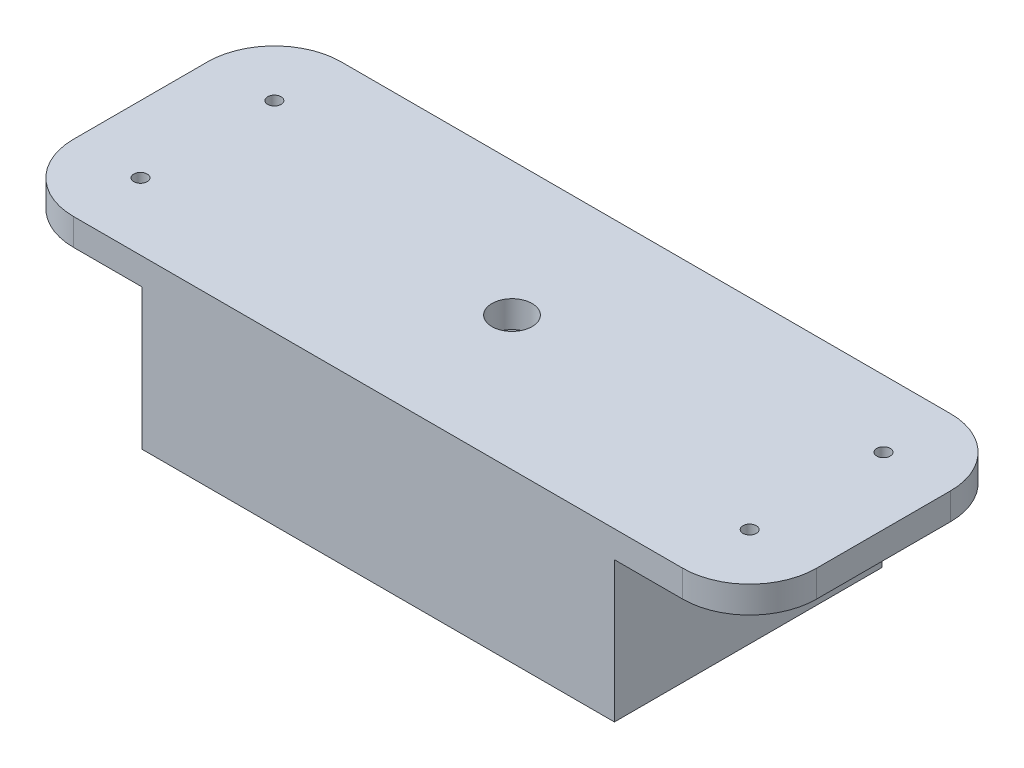
from build123d import *

# Parameters (mm, degrees)
SKETCH1_R           = 1
BOSS_EXTRUDE1_DEPTH = 4
BOSS_EXTRUDE3_DEPTH = 25
SKETCH3_R           = 3
CUT_EXTRUDE1_DEPTH  = 20


with BuildPart() as part:
    # Sketch1 → Boss-Extrude1 (new body)
    with BuildSketch(Plane(origin=(0, 0, 0), x_dir=(1, 0, 0), z_dir=(0, 1, 0))):
        with BuildLine():
            Line((-35.5, 20), (-35.5, 0))
            Line((-35.5, 0), (-35.5, -20))
            Line((-35.5, -20), (45.5, -20))
            ThreePointArc((45.5, -20), (52.571067812, -17.071067812), (55.5, -10))
            Line((55.5, -10), (55.5, 10))
            ThreePointArc((55.5, 10), (52.571067812, 17.071067812), (45.5, 20))
            Line((45.5, 20), (-35.5, 20))
        make_face()
        with Locations((45.5, -10)):
            Circle(SKETCH1_R, mode=Mode.SUBTRACT)
        Circle(SKETCH1_R, mode=Mode.SUBTRACT)
        with Locations((45.5, 10)):
            Circle(SKETCH1_R, mode=Mode.SUBTRACT)
        with BuildLine():
            Line((-35.5, -20), (-35.5, 0))
            Line((-35.5, 0), (-35.5, 20))
            Line((-35.5, 20), (-45.5, 20))
            ThreePointArc((-45.5, 20), (-52.571067812, 17.071067812), (-55.5, 10))
            Line((-55.5, 10), (-55.5, 0))
            Line((-55.5, 0), (-55.5, -10))
            ThreePointArc((-55.5, -10), (-52.571067812, -17.071067812), (-45.5, -20))
            Line((-45.5, -20), (-35.5, -20))
        make_face()
        with Locations((-45.5, -10)):
            Circle(SKETCH1_R, mode=Mode.SUBTRACT)
        with Locations((-45.5, 10)):
            Circle(SKETCH1_R, mode=Mode.SUBTRACT)
    extrude(amount=BOSS_EXTRUDE1_DEPTH)

    # Sketch2 → Boss-Extrude3 (add)
    with BuildSketch(Plane(origin=(0, 4, 0), x_dir=(1, 0, 0), z_dir=(0, 1, 0))):
        Polygon((-35.3, 0), (-35.3, -20), (35.3, -20), (35.3, 0), (35.3, 20), (-35.3, 20), align=None)
        Polygon((33.8, -18.5), (-33.8, -18.5), (-33.8, 0), (-33.8, 18.5), (33.8, 18.5), (33.8, 0), align=None, mode=Mode.SUBTRACT)
    extrude(amount=-BOSS_EXTRUDE3_DEPTH)

    # Sketch3 → Cut-Extrude1 (cut)
    with BuildSketch(Plane(origin=(0, 4, 0), x_dir=(1, 0, 0), z_dir=(0, 1, 0))):
        Circle(SKETCH3_R)
    extrude(amount=-CUT_EXTRUDE1_DEPTH, mode=Mode.SUBTRACT)


solid = part.part
